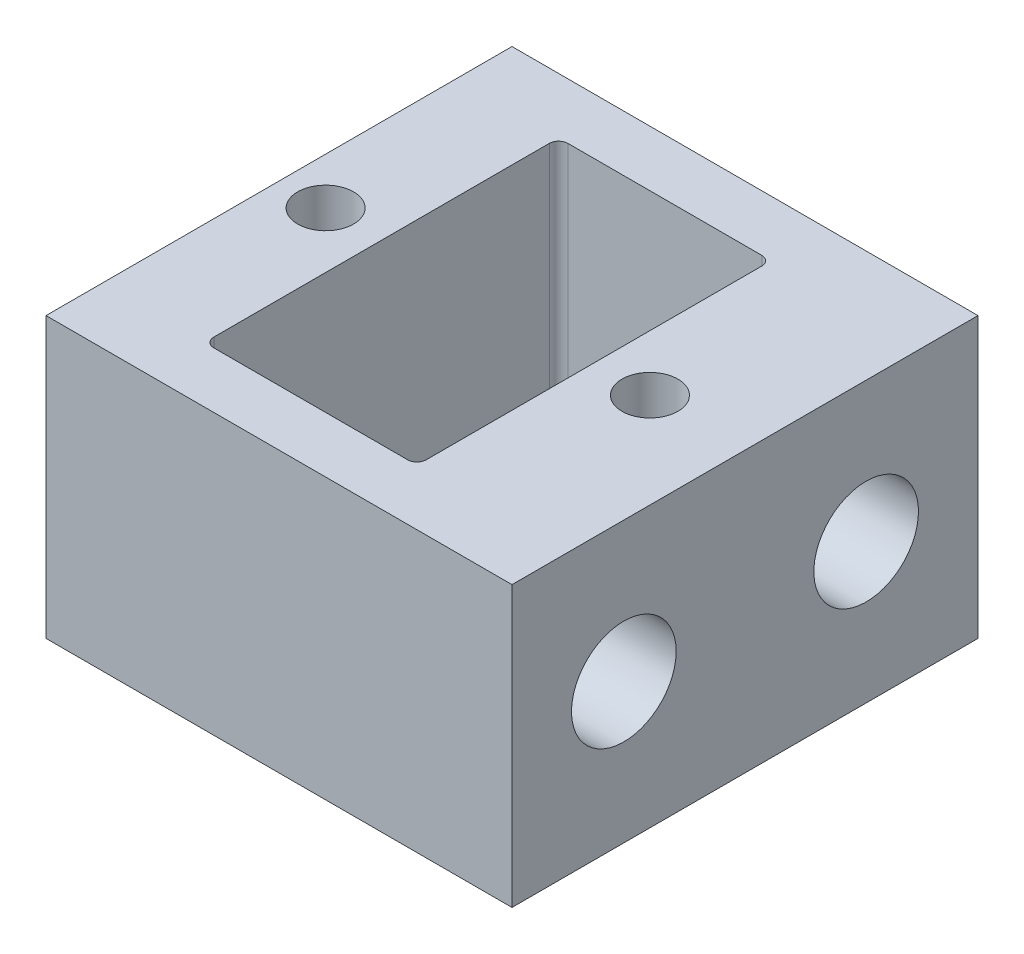
from build123d import *

# Parameters (mm, degrees)
SKETCH1_W             = 25
SKETCH1_H             = 25
BOSS_EXTRUDE1_DEPTH   = 15
SKETCH2_W             = 11.4
SKETCH2_H             = 19
CUT_EXTRUDE1_DEPTH    = 16
M3_CLEARANCE_HOLE1_D  = 3
FOR_M4_HEAT_SET_D     = 5.6134
FOR_M4_HEAT_SET_DEPTH = 8.1
FILLET1_R             = 0.5


with BuildPart() as part:
    # Sketch1 → Boss-Extrude1 (new body)
    with BuildSketch(Plane(origin=(0, 0, 0), x_dir=(1, 0, 0), z_dir=(0, 1, 0))):
        Rectangle(SKETCH1_W, SKETCH1_H)
    extrude(amount=BOSS_EXTRUDE1_DEPTH)

    # Sketch2 → Cut-Extrude1 (cut, through all)
    with BuildSketch(Plane(origin=(0, 15, 0), x_dir=(1, 0, 0), z_dir=(0, 1, 0))):
        with Locations((-1.3, 0)):
            Rectangle(SKETCH2_W, SKETCH2_H)
    extrude(amount=-CUT_EXTRUDE1_DEPTH, mode=Mode.SUBTRACT)

    # M3 Clearance Hole1 (through all)
    with Locations(Plane(origin=(0, 15, 0), x_dir=(1, 0, 0), z_dir=(0, 1, 0))):
        with Locations((-10, 0), (7.4, 0)):
            Hole(M3_CLEARANCE_HOLE1_D / 2)

    # for m4 heat set
    with Locations(Plane(origin=(12.5, 0, 0), x_dir=(0, 0, -1), z_dir=(1, 0, 0))):
        with Locations((-6.5, 7.5), (6.5, 7.5)):
            Hole(FOR_M4_HEAT_SET_D / 2, depth=FOR_M4_HEAT_SET_DEPTH)

    # Fillet1
    fillet1_edges = [part.edges().sort_by_distance(p)[0] for p in [
        (-7, 7.5, 9.5),
        (-7, 7.5, -9.5),
        (4.4, 7.5, -9.5),
        (4.4, 7.5, 9.5),
    ]]
    fillet(fillet1_edges, radius=FILLET1_R)


solid = part.part
